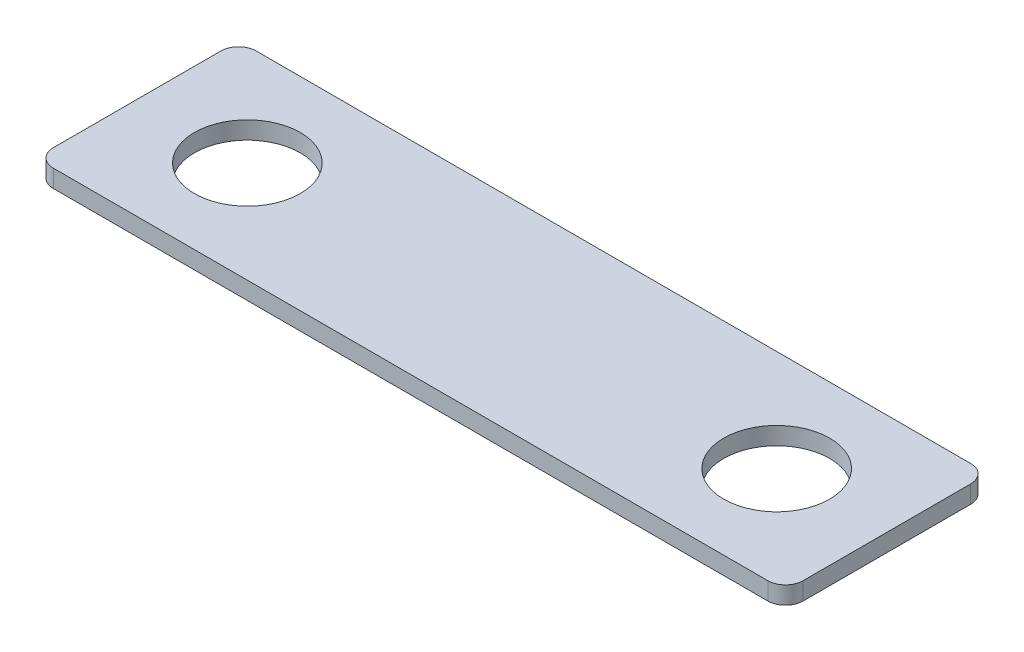
from build123d import *

# Parameters (mm, degrees)
EXTRUDE_1_DEPTH = 2


with BuildPart() as part:
    # Эскиз1 → Бобышка-Вытянуть1 (new body)
    with BuildSketch(Plane(origin=(0, 0, 0), x_dir=(1, 0, 0), z_dir=(0, 1, 0))):
        with BuildLine():
            Line((40.5, -11.5), (-40.5, -11.5))
            ThreePointArc((-40.5, -11.5), (-41.914213562, -10.914213562), (-42.5, -9.5))
            Line((-42.5, -9.5), (-42.5, 9.5))
            ThreePointArc((-42.5, 9.5), (-41.914213562, 10.914213562), (-40.5, 11.5))
            Line((-40.5, 11.5), (40.5, 11.5))
            ThreePointArc((40.5, 11.5), (41.914213562, 10.914213562), (42.5, 9.5))
            Line((42.5, 9.5), (42.5, -9.5))
            ThreePointArc((42.5, -9.5), (41.914213562, -10.914213562), (40.5, -11.5))
        make_face()
        with BuildLine():
            ThreePointArc((-30, 6), (-36, 0), (-30, -6))
            ThreePointArc((-30, -6), (-24, 0), (-30, 6))
        make_face(mode=Mode.SUBTRACT)
        with BuildLine():
            ThreePointArc((30, 6), (36, 0), (30, -6))
            ThreePointArc((30, -6), (24, 0), (30, 6))
        make_face(mode=Mode.SUBTRACT)
    extrude(amount=EXTRUDE_1_DEPTH)


solid = part.part
